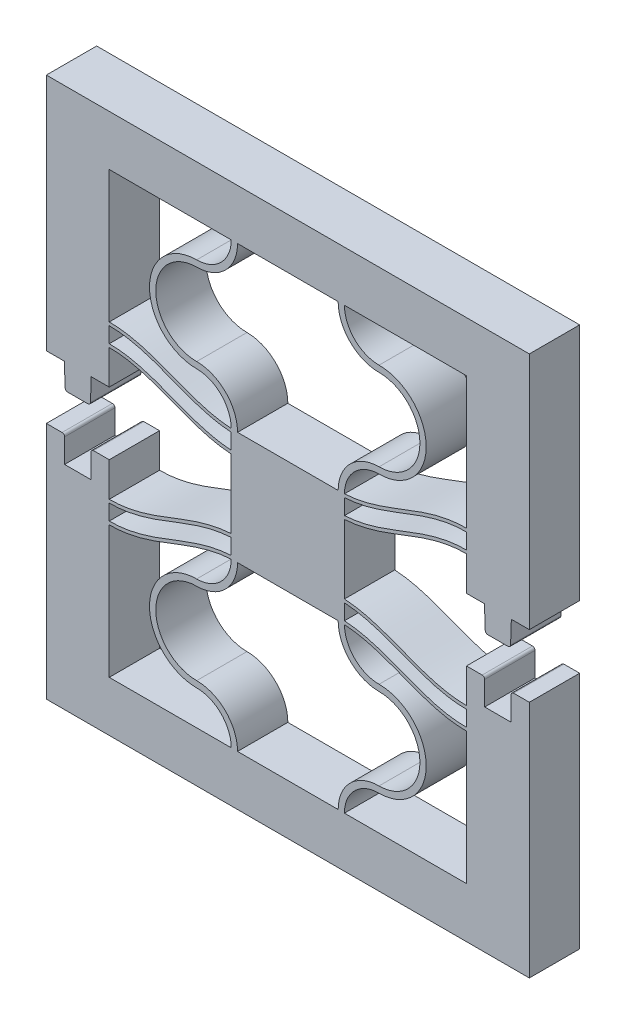
from build123d import *

# Parameters (mm, degrees)
BOSS_EXTRUDE1_DEPTH = 4
SKETCH4_W           = 1.000079602
SKETCH4_H           = 4
BOSS_EXTRUDE2_DEPTH = 1.5
SKETCH7_W           = 4
SKETCH7_H           = 4
SKETCH7_H_2         = 8.970409071
BOSS_EXTRUDE3_DEPTH = 4
SKETCH8_W           = 5.000000005
SKETCH8_H           = 2.725204932
BOSS_EXTRUDE4_DEPTH = 4
SKETCH9_W           = 2
SKETCH9_H           = 2
BOSS_EXTRUDE5_DEPTH = 4
SKETCH10_W          = 2.1
SKETCH10_H          = 2.1
CUT_EXTRUDE1_DEPTH  = 4
DRAFT1_ANGLE        = 2
FILLET1_R           = 0.2


with BuildPart() as part:
    # Sketch1 → Boss-Extrude1 (new body)
    with BuildSketch(Plane.XY):
        with BuildLine():
            add(Edge.make_bspline(
                [(10.700039975, 14.745204536), (10.770772559, 14.741026808), (11.036928883, 14.722362813), (11.497122592, 14.671037325), (12.289279781, 14.528352814), (13.186428125, 14.281886639), (13.972953946, 14.012479628), (14.659814487, 13.755888369), (15.208666695, 13.545451258), (15.665563716, 13.368818224), (16.123450769, 13.194753096), (16.65208653, 13.002369042), (17.160327646, 12.828079612), (17.673887847, 12.669729106), (18.193716878, 12.533320658), (18.599888692, 12.444944264), (18.888931626, 12.391496574), (19.130919694, 12.353423685), (19.325052629, 12.327000657), (19.519580514, 12.304753805), (19.715757224, 12.286804034), (19.909026191, 12.273251391), (20.101721437, 12.264172749), (20.275673832, 12.260758352), (20.359000366, 12.259999604), (20.4, 12.259999604)],
                knots=[0.519813033, 0.519813033, 0.519813033, 0.519813033, 0.519813033, 0.531036625, 0.562073255, 0.593109869, 0.647173692, 0.678210339, 0.693728663, 0.709246987, 0.740283631, 0.755801952, 0.771320274, 0.79835218, 0.825384086, 0.84090241, 0.856420734, 0.86417989, 0.871939045, 0.8796982, 0.887457356, 0.89521651, 0.902975665, 0.910734819, 0.918493974, 0.918493974, 0.918493974, 0.918493974, 0.918493974], degree=4))
            Line((10.700039975, 14.745204536), (10.700039975, 15.985204536))
            Line((10.700039975, 15.985204536), (9.699960373, 15.985204536))
            Line((9.699960373, 15.985204536), (9.699960373, 14.745204536))
            add(Edge.make_bspline(
                [(0, 12.259999604), (0.040999634, 12.259999604), (0.124259479, 12.260758348), (0.355363371, 12.265310827), (0.583318983, 12.278545215), (0.832717182, 12.299192103), (1.123166493, 12.332562429), (1.414830156, 12.374284724), (1.752116289, 12.434526897), (2.206359313, 12.533321163), (2.726048123, 12.669728195), (3.239713703, 12.828081076), (3.7478924, 13.002367086), (4.184493287, 13.161250769), (4.551277809, 13.299188315), (4.917195343, 13.439475144), (5.282809261, 13.580521779), (5.740185056, 13.755889696), (6.427046416, 14.012478612), (7.213571652, 14.281887279), (8.110720324, 14.528352483), (8.902877469, 14.671037458), (9.363071278, 14.722362846), (9.629227699, 14.741026811), (9.699960373, 14.745204536)],
                knots=[0.081506026, 0.081506026, 0.081506026, 0.081506026, 0.081506026, 0.089265181, 0.097024335, 0.112542644, 0.1203018, 0.128060955, 0.143579266, 0.15909759, 0.174615914, 0.20164782, 0.228679726, 0.244198048, 0.259716369, 0.275234691, 0.290753013, 0.306271337, 0.321789661, 0.352826308, 0.406890131, 0.437926745, 0.468963375, 0.480186981, 0.480186981, 0.480186981, 0.480186981, 0.480186981], degree=4))
            Line((0, 12.259999604), (-5.000000005, 12.259999604))
            Line((-5.000000005, 12.259999604), (-5.000000005, -4))
            Line((-5.000000005, -4), (25.400000005, -4))
            Line((25.400000005, -4), (25.400000005, 12.259999604))
            Line((25.400000005, 12.259999604), (20.4, 12.259999604))
        make_face()
        with BuildLine():
            Line((9.699960373, 14.485204536), (9.699960373, 13.245204536))
            add(Edge.make_bspline(
                [(0, 10.759999604), (0.040999634, 10.759999604), (0.124259479, 10.760758348), (0.355363371, 10.765310827), (0.583318983, 10.778545215), (0.832717182, 10.799192103), (1.123166493, 10.832562429), (1.414830156, 10.874284724), (1.752116289, 10.934526897), (2.206359313, 11.033321163), (2.726048123, 11.169728195), (3.239713703, 11.328081076), (3.7478924, 11.502367086), (4.184493287, 11.661250769), (4.551277809, 11.799188315), (4.917195343, 11.939475144), (5.282809261, 12.080521779), (5.740185056, 12.255889696), (6.427046416, 12.512478612), (7.213571652, 12.781887279), (8.110720324, 13.028352483), (8.902877469, 13.171037458), (9.363071278, 13.222362846), (9.629227699, 13.241026811), (9.699960373, 13.245204536)],
                knots=[0.081506026, 0.081506026, 0.081506026, 0.081506026, 0.081506026, 0.089265181, 0.097024335, 0.112542644, 0.1203018, 0.128060955, 0.143579266, 0.15909759, 0.174615914, 0.20164782, 0.228679726, 0.244198048, 0.259716369, 0.275234691, 0.290753013, 0.306271337, 0.321789661, 0.352826308, 0.406890131, 0.437926745, 0.468963375, 0.480186981, 0.480186981, 0.480186981, 0.480186981, 0.480186981], degree=4))
            Line((0, 10.759999604), (0, 11.999999604))
            add(Edge.make_bspline(
                [(0, 11.999999604), (0.040999634, 11.999999604), (0.124259479, 12.000758348), (0.355363371, 12.005310827), (0.583318983, 12.018545215), (0.832717182, 12.039192103), (1.123166493, 12.072562429), (1.414830156, 12.114284724), (1.752116289, 12.174526897), (2.206359313, 12.273321163), (2.726048123, 12.409728195), (3.239713703, 12.568081076), (3.7478924, 12.742367086), (4.184493287, 12.901250769), (4.551277809, 13.039188315), (4.917195343, 13.179475144), (5.282809261, 13.320521779), (5.740185056, 13.495889696), (6.427046416, 13.752478612), (7.213571652, 14.021887279), (8.110720324, 14.268352483), (8.902877469, 14.411037458), (9.363071278, 14.462362846), (9.629227699, 14.481026811), (9.699960373, 14.485204536)],
                knots=[0.081506026, 0.081506026, 0.081506026, 0.081506026, 0.081506026, 0.089265181, 0.097024335, 0.112542644, 0.1203018, 0.128060955, 0.143579266, 0.15909759, 0.174615914, 0.20164782, 0.228679726, 0.244198048, 0.259716369, 0.275234691, 0.290753013, 0.306271337, 0.321789661, 0.352826308, 0.406890131, 0.437926745, 0.468963375, 0.480186981, 0.480186981, 0.480186981, 0.480186981, 0.480186981], degree=4))
        make_face(mode=Mode.SUBTRACT)
        with BuildLine():
            Line((10.700039975, 13.245204536), (10.700039975, 14.485204536))
            add(Edge.make_bspline(
                [(10.700039975, 14.485204536), (10.770772559, 14.481026808), (11.036928883, 14.462362813), (11.497122592, 14.411037325), (12.289279781, 14.268352814), (13.186428125, 14.021886639), (13.972953947, 13.752479628), (14.659814487, 13.495888369), (15.208666695, 13.285451258), (15.665563716, 13.108818224), (16.123450769, 12.934753096), (16.65208653, 12.742369042), (17.160327646, 12.568079612), (17.673887847, 12.409729106), (18.193716878, 12.273320658), (18.599888692, 12.184944264), (18.888931626, 12.131496574), (19.130919694, 12.093423685), (19.325052629, 12.067000657), (19.519580514, 12.044753805), (19.715757224, 12.026804034), (19.909026191, 12.013251391), (20.101721437, 12.004172749), (20.275673832, 12.000758352), (20.359000366, 11.999999604), (20.4, 11.999999604)],
                knots=[0.519813033, 0.519813033, 0.519813033, 0.519813033, 0.519813033, 0.531036625, 0.562073255, 0.593109869, 0.647173692, 0.678210339, 0.693728663, 0.709246987, 0.740283631, 0.755801952, 0.771320274, 0.79835218, 0.825384086, 0.84090241, 0.856420734, 0.86417989, 0.871939045, 0.8796982, 0.887457356, 0.89521651, 0.902975665, 0.910734819, 0.918493974, 0.918493974, 0.918493974, 0.918493974, 0.918493974], degree=4))
            Line((20.4, 11.999999604), (20.4, 10.759999604))
            add(Edge.make_bspline(
                [(10.700039975, 13.245204536), (10.770772559, 13.241026808), (11.036928883, 13.222362813), (11.497122592, 13.171037325), (12.289279781, 13.028352814), (13.186428125, 12.781886639), (13.972953947, 12.512479628), (14.659814487, 12.255888369), (15.208666695, 12.045451258), (15.665563716, 11.868818224), (16.123450769, 11.694753096), (16.65208653, 11.502369042), (17.160327646, 11.328079612), (17.673887847, 11.169729106), (18.193716878, 11.033320658), (18.599888692, 10.944944264), (18.888931626, 10.891496574), (19.130919694, 10.853423685), (19.325052629, 10.827000657), (19.519580514, 10.804753805), (19.715757224, 10.786804034), (19.909026191, 10.773251391), (20.101721437, 10.764172749), (20.275673832, 10.760758352), (20.359000366, 10.759999604), (20.4, 10.759999604)],
                knots=[0.519813033, 0.519813033, 0.519813033, 0.519813033, 0.519813033, 0.531036625, 0.562073255, 0.593109869, 0.647173692, 0.678210339, 0.693728663, 0.709246987, 0.740283631, 0.755801952, 0.771320274, 0.79835218, 0.825384086, 0.84090241, 0.856420734, 0.86417989, 0.871939045, 0.8796982, 0.887457356, 0.89521651, 0.902975665, 0.910734819, 0.918493974, 0.918493974, 0.918493974, 0.918493974, 0.918493974], degree=4))
        make_face(mode=Mode.SUBTRACT)
        with BuildLine():
            Line((0, 0), (0, 10.499999604))
            add(Edge.make_bspline(
                [(0, 10.499999604), (0.040999634, 10.499999604), (0.124259479, 10.500758348), (0.355363371, 10.505310827), (0.583318983, 10.518545215), (0.832717182, 10.539192103), (1.123166493, 10.572562429), (1.414830156, 10.614284724), (1.752116289, 10.674526897), (2.206359313, 10.773321163), (2.726048123, 10.909728195), (3.239713703, 11.068081076), (3.7478924, 11.242367086), (4.184493287, 11.401250769), (4.551277809, 11.539188315), (4.917195343, 11.679475144), (5.282809261, 11.820521779), (5.740185056, 11.995889696), (6.427046416, 12.252478612), (7.213571652, 12.521887279), (8.110720324, 12.768352483), (8.902877469, 12.911037458), (9.363071278, 12.962362846), (9.629227699, 12.981026811), (9.699960373, 12.985204536)],
                knots=[0.081506026, 0.081506026, 0.081506026, 0.081506026, 0.081506026, 0.089265181, 0.097024335, 0.112542644, 0.1203018, 0.128060955, 0.143579266, 0.15909759, 0.174615914, 0.20164782, 0.228679726, 0.244198048, 0.259716369, 0.275234691, 0.290753013, 0.306271337, 0.321789661, 0.352826308, 0.406890131, 0.437926745, 0.468963375, 0.480186981, 0.480186981, 0.480186981, 0.480186981, 0.480186981], degree=4))
            ThreePointArc((9.699960373, 12.985204536), (8.889305781, 11.050232382), (6.950000174, 10.25))
            ThreePointArc((6.950000174, 10.25), (3.200000174, 6.5), (6.950000174, 2.75))
            ThreePointArc((6.950000174, 2.75), (8.894543822, 1.944543648), (9.700000174, 0))
            Line((9.700000174, 0), (0, 0))
        make_face(mode=Mode.SUBTRACT)
        with BuildLine():
            ThreePointArc((6.950000174, 9.75), (9.248097213, 10.701902961), (10.200000174, 13))
            ThreePointArc((10.200000174, 13), (11.151903135, 10.701902961), (13.450000174, 9.75))
            ThreePointArc((13.450000174, 9.75), (16.700000174, 6.5), (13.450000174, 3.25))
            ThreePointArc((13.450000174, 3.25), (11.151903135, 2.298097039), (10.200000174, 0))
            ThreePointArc((10.200000174, 0), (9.248097213, 2.298097039), (6.950000174, 3.25))
            ThreePointArc((6.950000174, 3.25), (3.700000174, 6.5), (6.950000174, 9.75))
        make_face(mode=Mode.SUBTRACT)
        with BuildLine():
            ThreePointArc((13.450000174, 10.25), (11.510694567, 11.050232382), (10.700039975, 12.985204536))
            add(Edge.make_bspline(
                [(10.700039975, 12.985204536), (10.770772559, 12.981026808), (11.036928883, 12.962362813), (11.497122592, 12.911037325), (12.289279781, 12.768352814), (13.186428125, 12.521886639), (13.972953947, 12.252479628), (14.659814487, 11.995888369), (15.208666695, 11.785451258), (15.665563716, 11.608818224), (16.123450769, 11.434753096), (16.65208653, 11.242369042), (17.160327646, 11.068079612), (17.673887847, 10.909729106), (18.193716878, 10.773320658), (18.599888692, 10.684944264), (18.888931626, 10.631496574), (19.130919694, 10.593423685), (19.325052629, 10.567000657), (19.519580514, 10.544753805), (19.715757224, 10.526804034), (19.909026191, 10.513251391), (20.101721437, 10.504172749), (20.275673832, 10.500758352), (20.359000366, 10.499999604), (20.4, 10.499999604)],
                knots=[0.519813033, 0.519813033, 0.519813033, 0.519813033, 0.519813033, 0.531036625, 0.562073255, 0.593109869, 0.647173692, 0.678210339, 0.693728663, 0.709246987, 0.740283631, 0.755801952, 0.771320274, 0.79835218, 0.825384086, 0.84090241, 0.856420734, 0.86417989, 0.871939045, 0.8796982, 0.887457356, 0.89521651, 0.902975665, 0.910734819, 0.918493974, 0.918493974, 0.918493974, 0.918493974, 0.918493974], degree=4))
            Line((20.4, 10.499999604), (20.4, 0))
            Line((20.4, 0), (10.700000174, 0))
            ThreePointArc((10.700000174, 0), (11.505456526, 1.944543648), (13.450000174, 2.75))
            ThreePointArc((13.450000174, 2.75), (17.200000174, 6.5), (13.450000174, 10.25))
        make_face(mode=Mode.SUBTRACT)
    extrude(amount=BOSS_EXTRUDE1_DEPTH)

    # Sketch4 → Boss-Extrude2 (add)
    with BuildSketch(Plane(origin=(0, 15.985204536, 0), x_dir=(1, 0, 0), z_dir=(0, 1, 0))):
        with Locations((10.200000174, -2)):
            Rectangle(SKETCH4_W, SKETCH4_H)
    extrude(amount=BOSS_EXTRUDE2_DEPTH)

    # Mirror3: part across plane


with BuildPart() as part_1:
    add(part.part)
    add(part.part.mirror(Plane.ZX.offset(17.485204536)))

    # Split2
    split(bisect_by=Plane(origin=(10.200000174, 0, 0), x_dir=(0, -1, 0), z_dir=(-1, 0, 0)), keep=Keep.BOTTOM)

    # Sketch7 → Boss-Extrude3 (add)
    with BuildSketch(Plane.ZY.offset(-10.200000174)):
        with Locations((2, 36.970409071)):
            Rectangle(SKETCH7_W, SKETCH7_H)
        with Locations((2, 17.485204536)):
            Rectangle(SKETCH7_W, SKETCH7_H_2)
        with Locations((2, -2)):
            Rectangle(SKETCH7_W, SKETCH7_H)
    extrude(amount=BOSS_EXTRUDE3_DEPTH)

    # Mirror2: part across plane


with BuildPart() as part_2:
    add(part_1.part)
    add(part_1.part.mirror(Plane.ZY.offset(-6.200000174)))

    # Sketch8 → Boss-Extrude4 (add)
    with BuildSketch(Plane.XY.offset(4)):
        with Locations((-10.499999654, 21.347807002)):
            Rectangle(SKETCH8_W, SKETCH8_H)
        with Locations((-10.499999654, 13.62260207)):
            Rectangle(SKETCH8_W, SKETCH8_H)
        with Locations((22.900000003, 13.62260207)):
            Rectangle(SKETCH8_W, SKETCH8_H)
        with Locations((22.900000003, 21.347807002)):
            Rectangle(SKETCH8_W, SKETCH8_H)
    extrude(amount=-BOSS_EXTRUDE4_DEPTH)

    # Sketch9 → Boss-Extrude5 (add)
    with BuildSketch(Plane.XY.offset(4)):
        with Locations((-10.499999655, 18.985204536)):
            Rectangle(SKETCH9_W, SKETCH9_H)
        with Locations((22.900000003, 18.985204536)):
            Rectangle(SKETCH9_W, SKETCH9_H)
    extrude(amount=-BOSS_EXTRUDE5_DEPTH)

    # Sketch10 → Cut-Extrude1 (cut)
    with BuildSketch(Plane.XY.offset(4)):
        with Locations((-10.499999655, 13.935204536)):
            Rectangle(SKETCH10_W, SKETCH10_H)
        with Locations((22.900000003, 13.935204536)):
            Rectangle(SKETCH10_W, SKETCH10_H)
    extrude(amount=-CUT_EXTRUDE1_DEPTH, mode=Mode.SUBTRACT)

    # Draft1
    draft1_faces = [part_2.faces().sort_by_distance(p)[0] for p in [
        (23.900000003, 18.985204536, 2),
        (21.900000003, 18.985204536, 2),
        (-9.499999655, 18.985204536, 2),
        (-11.499999655, 18.985204536, 2),
    ]]
    draft(draft1_faces, Plane(origin=(-9.499999655, 17.985204536, -2.828427125), x_dir=(0, 0, -1), z_dir=(0, -1, 0)), DRAFT1_ANGLE)

    # Fillet1
    fillet1_edges = [part_2.edges().sort_by_distance(p)[0] for p in [
        (-9.499999655, 17.985204536, 2),
        (-11.499999655, 17.985204536, 2),
        (21.900000003, 17.985204536, 2),
        (23.900000003, 17.985204536, 2),
        (-9.449999655, 14.985204536, 2),
        (-11.549999655, 14.985204536, 2),
        (21.850000003, 14.985204536, 2),
        (23.950000003, 14.985204536, 2),
    ]]
    fillet(fillet1_edges, radius=FILLET1_R)


solid = part_2.part
